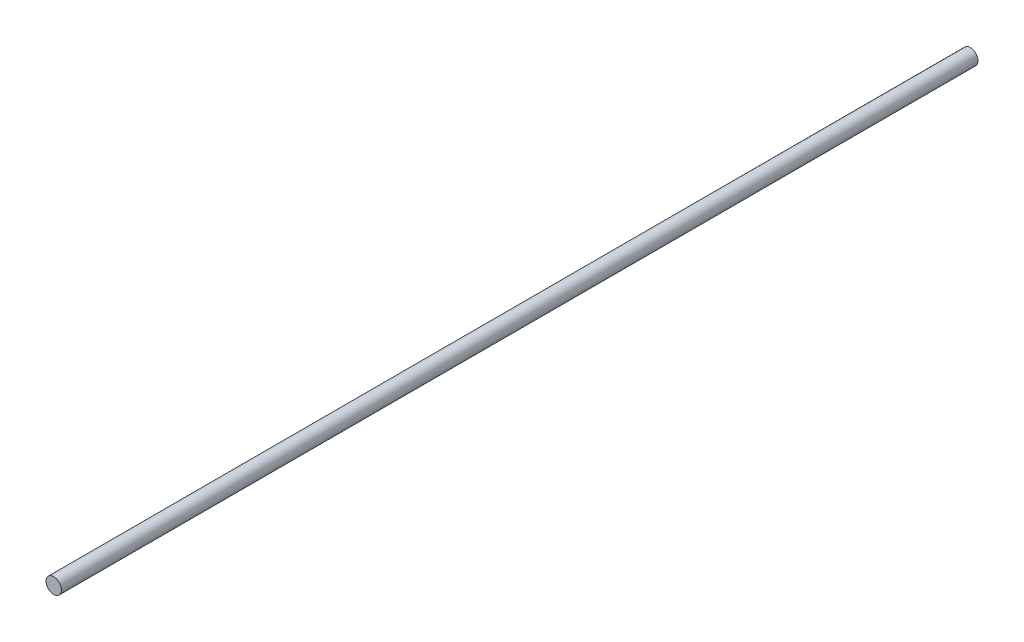
from build123d import *

# Parameters (mm, degrees)
ESQUISSE1_R        = 2
BOSS_EXTRU_1_DEPTH = 238


with BuildPart() as part:
    # Esquisse1 → Boss.-Extru.1 (new body)
    with BuildSketch(Plane.XY):
        Circle(ESQUISSE1_R)
    extrude(amount=BOSS_EXTRU_1_DEPTH)


solid = part.part
